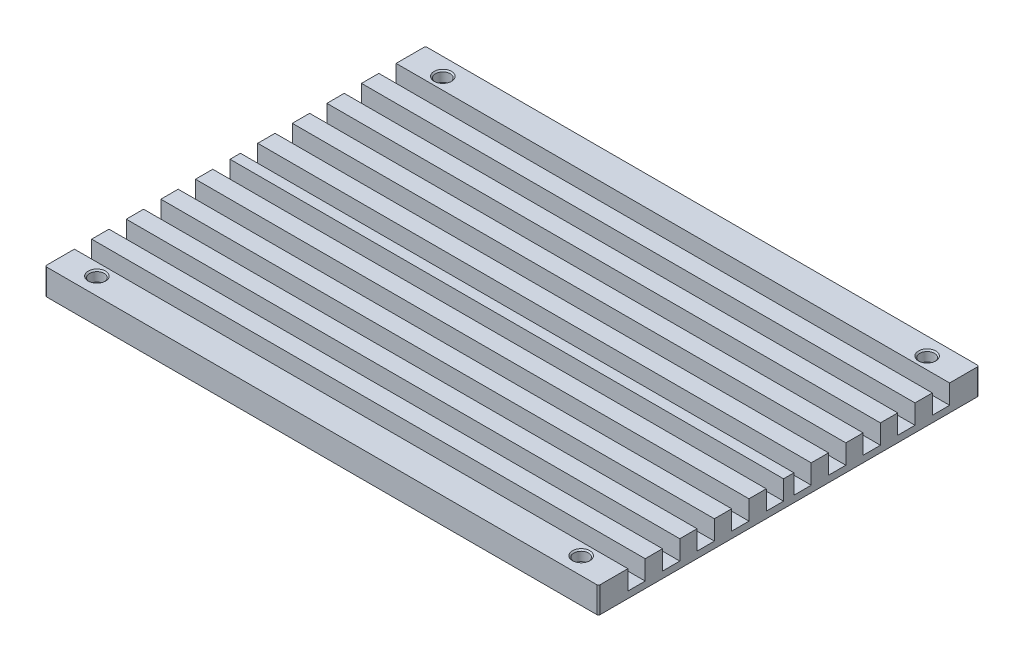
from build123d import *

# Parameters (mm, degrees)
SKETCH1_W                                    = 320
SKETCH1_H                                    = 220
BOSS_EXTRUDE1_DEPTH                          = 15
FILLET2_R                                    = 1
CBORE_FOR_M5_HEX_SOCKET_HEAD_CAP_SCR_2_COUNT = 2
CBORE_FOR_M5_HEX_SOCKET_HEAD_CAP_SCR_2_PITCH = 200
CBORE_FOR_M5_HEX_SOCKET_HEAD_CAP_SCR_3_COUNT = 2
CBORE_FOR_M5_HEX_SOCKET_HEAD_CAP_SCR_3_PITCH = 344.093010682
CBORE_FOR_M5_HEX_SOCKET_HEAD_CAP_SCR_4_COUNT = 2
CBORE_FOR_M5_HEX_SOCKET_HEAD_CAP_SCR_4_PITCH = 280
SKETCH7_W                                    = 10
SKETCH7_H                                    = 11.203973801
CUT_EXTRUDE1_DEPTH                           = 321


with BuildPart() as part:
    # Sketch1 → Boss-Extrude1 (new body)
    with BuildSketch(Plane(origin=(0, 0, 0), x_dir=(1, 0, 0), z_dir=(0, 1, 0))):
        Rectangle(SKETCH1_W, SKETCH1_H)
    extrude(amount=BOSS_EXTRUDE1_DEPTH)

    # Fillet2
    fillet2_edges = [part.edges().sort_by_distance(p)[0] for p in [
        (-160, 7.5, -110),
        (160, 7.5, -110),
        (160, 7.5, 110),
        (-160, 7.5, 110),
    ]]
    fillet(fillet2_edges, radius=FILLET2_R)

    # Sketch5 → CBORE for M5 Hex Socket Head Cap Screw2 (revolve, cut)
    with BuildSketch(Plane(origin=(-140, 15, -100), x_dir=(0, 0, 1), z_dir=(1, 0, 0))):
        Polygon((0, 0), (0, 15), (2.75, 15), (2.75, 6), (4.25, 6), (4.25, 0.775), (5.025, 0), align=None)
    cbore_for_m5_hex_socket_head_cap_screw2 = revolve(axis=Axis((-140, 21.35, -100), (0, -1, 0)), mode=Mode.SUBTRACT)

    # CBORE for M5 Hex Socket Head Cap Scr 2: CBORE for M5 Hex Socket Head Cap Screw2 ×2
    with Locations(*[(0, 0, i * CBORE_FOR_M5_HEX_SOCKET_HEAD_CAP_SCR_2_PITCH) for i in range(1, CBORE_FOR_M5_HEX_SOCKET_HEAD_CAP_SCR_2_COUNT)]):
        add(cbore_for_m5_hex_socket_head_cap_screw2, mode=Mode.SUBTRACT)

    # CBORE for M5 Hex Socket Head Cap Scr 3: CBORE for M5 Hex Socket Head Cap Screw2 ×2
    with Locations(*[Vector(0.813733471, 0, 0.581238194) * (i * CBORE_FOR_M5_HEX_SOCKET_HEAD_CAP_SCR_3_PITCH) for i in range(1, CBORE_FOR_M5_HEX_SOCKET_HEAD_CAP_SCR_3_COUNT)]):
        add(cbore_for_m5_hex_socket_head_cap_screw2, mode=Mode.SUBTRACT)

    # CBORE for M5 Hex Socket Head Cap Scr 4: CBORE for M5 Hex Socket Head Cap Screw2 ×2
    with Locations(*[(i * CBORE_FOR_M5_HEX_SOCKET_HEAD_CAP_SCR_4_PITCH, 0, 0) for i in range(1, CBORE_FOR_M5_HEX_SOCKET_HEAD_CAP_SCR_4_COUNT)]):
        add(cbore_for_m5_hex_socket_head_cap_screw2, mode=Mode.SUBTRACT)

    # Sketch7 → Cut-Extrude1 (cut, through all)
    with BuildSketch(Plane.ZY.offset(160)):
        with Locations((-88, 9.3980131)):
            Rectangle(SKETCH7_W, SKETCH7_H)
        with Locations((8, 9.3980131)):
            Rectangle(SKETCH7_W, SKETCH7_H)
        with Locations((-68, 9.3980131)):
            Rectangle(SKETCH7_W, SKETCH7_H)
        with Locations((-48, 9.3980131)):
            Rectangle(SKETCH7_W, SKETCH7_H)
        with Locations((-28, 9.3980131)):
            Rectangle(SKETCH7_W, SKETCH7_H)
        with Locations((-8, 9.3980131)):
            Rectangle(SKETCH7_W, SKETCH7_H)
        with Locations((28, 9.3980131)):
            Rectangle(SKETCH7_W, SKETCH7_H)
        with Locations((48, 9.3980131)):
            Rectangle(SKETCH7_W, SKETCH7_H)
        with Locations((68, 9.3980131)):
            Rectangle(SKETCH7_W, SKETCH7_H)
        with Locations((88, 9.3980131)):
            Rectangle(SKETCH7_W, SKETCH7_H)
    extrude(amount=-CUT_EXTRUDE1_DEPTH, mode=Mode.SUBTRACT)


solid = part.part
